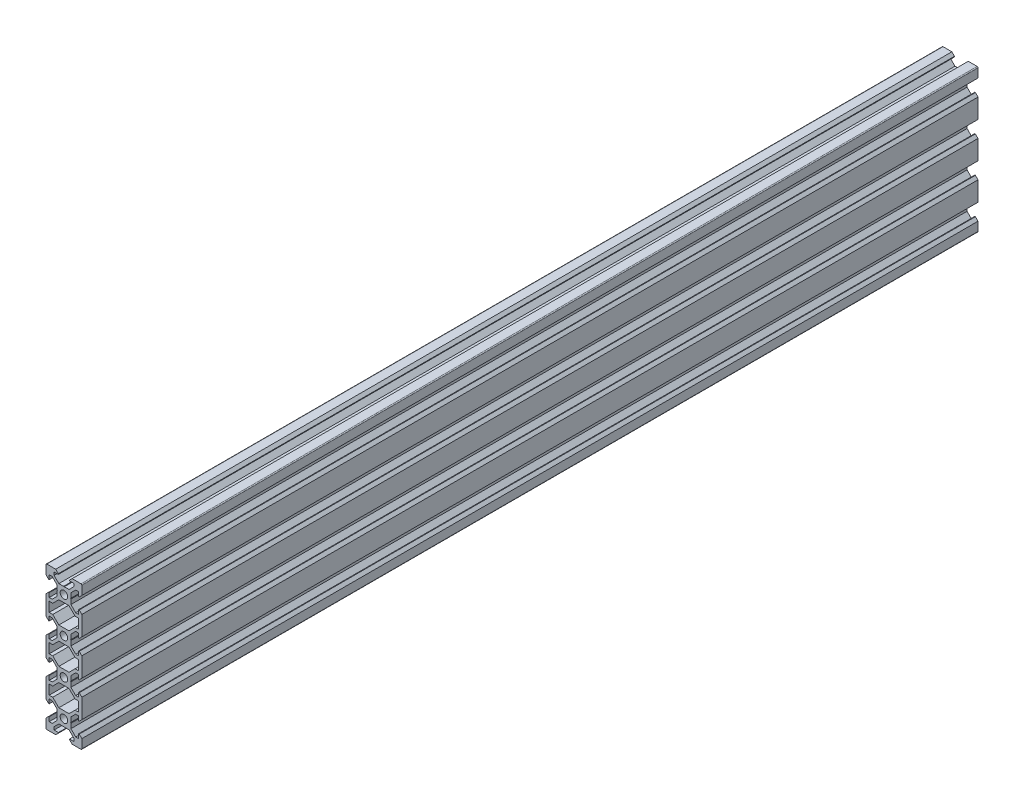
from build123d import *

# Parameters (mm, degrees)
SKETCH1_R           = 2.1
BOSS_EXTRUDE1_DEPTH = 500


with BuildPart() as part:
    # Sketch1 → Boss-Extrude1 (new body)
    with BuildSketch(Plane.XY):
        with BuildLine():
            Line((4.58, -40), (9.5, -40))
            ThreePointArc((9.5, -40), (9.853553391, -39.853553391), (10, -39.5))
            Line((10, -39.5), (10, -34.58))
            Line((10, -34.58), (8.545, -33.125))
            Line((8.545, -33.125), (8.2, -33.125))
            Line((8.2, -33.125), (8.2, -35.5))
            Line((8.2, -35.5), (6.560660172, -35.5))
            Line((6.560660172, -35.5), (3.9, -32.839339828))
            Line((3.9, -32.839339828), (3.9, -30.21))
            Line((3.9, -30.21), (3.69, -30))
            Line((3.69, -30), (3.9, -29.79))
            Line((3.9, -29.79), (3.9, -27.160660172))
            Line((3.9, -27.160660172), (6.560660172, -24.5))
            Line((6.560660172, -24.5), (8.2, -24.5))
            Line((8.2, -24.5), (8.2, -26.875))
            Line((8.2, -26.875), (8.545, -26.875))
            Line((8.545, -26.875), (10, -25.42))
            Line((10, -25.42), (10, -14.58))
            Line((10, -14.58), (8.545, -13.125))
            Line((8.545, -13.125), (8.2, -13.125))
            Line((8.2, -13.125), (8.2, -15.5))
            Line((8.2, -15.5), (6.560660172, -15.5))
            Line((6.560660172, -15.5), (3.9, -12.839339828))
            Line((3.9, -12.839339828), (3.9, -10.21))
            Line((3.9, -10.21), (3.69, -10))
            Line((3.69, -10), (3.9, -9.79))
            Line((3.9, -9.79), (3.9, -7.160660172))
            Line((3.9, -7.160660172), (6.560660172, -4.5))
            Line((6.560660172, -4.5), (8.2, -4.5))
            Line((8.2, -4.5), (8.2, -6.875))
            Line((8.2, -6.875), (8.545, -6.875))
            Line((8.545, -6.875), (10, -5.42))
            Line((10, -5.42), (10, 5.42))
            Line((10, 5.42), (8.545, 6.875))
            Line((8.545, 6.875), (8.2, 6.875))
            Line((8.2, 6.875), (8.2, 4.5))
            Line((8.2, 4.5), (6.560660172, 4.5))
            Line((6.560660172, 4.5), (3.9, 7.160660172))
            Line((3.9, 7.160660172), (3.9, 9.79))
            Line((3.9, 9.79), (3.69, 10))
            Line((3.69, 10), (3.9, 10.21))
            Line((3.9, 10.21), (3.9, 12.839339828))
            Line((3.9, 12.839339828), (6.560660172, 15.5))
            Line((6.560660172, 15.5), (8.2, 15.5))
            Line((8.2, 15.5), (8.2, 13.125))
            Line((8.2, 13.125), (8.545, 13.125))
            Line((8.545, 13.125), (10, 14.58))
            Line((10, 14.58), (10, 25.42))
            Line((10, 25.42), (8.545, 26.875))
            Line((8.545, 26.875), (8.2, 26.875))
            Line((8.2, 26.875), (8.2, 24.5))
            Line((8.2, 24.5), (6.560660172, 24.5))
            Line((6.560660172, 24.5), (3.9, 27.160660172))
            Line((3.9, 27.160660172), (3.9, 29.79))
            Line((3.9, 29.79), (3.69, 30))
            Line((3.69, 30), (3.9, 30.21))
            Line((3.9, 30.21), (3.9, 32.839339828))
            Line((3.9, 32.839339828), (6.560660172, 35.5))
            Line((6.560660172, 35.5), (8.2, 35.5))
            Line((8.2, 35.5), (8.2, 33.125))
            Line((8.2, 33.125), (8.545, 33.125))
            Line((8.545, 33.125), (10, 34.58))
            Line((10, 34.58), (10, 39.5))
            ThreePointArc((10, 39.5), (9.853553391, 39.853553391), (9.5, 40))
            Line((9.5, 40), (4.58, 40))
            Line((4.58, 40), (3.125, 38.545))
            Line((3.125, 38.545), (3.125, 38.2))
            Line((3.125, 38.2), (5.5, 38.2))
            Line((5.5, 38.2), (5.5, 36.560660172))
            Line((5.5, 36.560660172), (2.839339828, 33.9))
            Line((2.839339828, 33.9), (0.21, 33.9))
            Line((0.21, 33.9), (0, 33.69))
            Line((0, 33.69), (-0.21, 33.9))
            Line((-0.21, 33.9), (-2.839339828, 33.9))
            Line((-2.839339828, 33.9), (-5.5, 36.560660172))
            Line((-5.5, 36.560660172), (-5.5, 38.2))
            Line((-5.5, 38.2), (-3.125, 38.2))
            Line((-3.125, 38.2), (-3.125, 38.545))
            Line((-3.125, 38.545), (-4.58, 40))
            Line((-4.58, 40), (-9.5, 40))
            ThreePointArc((-9.5, 40), (-9.853553391, 39.853553391), (-10, 39.5))
            Line((-10, 39.5), (-10, 34.58))
            Line((-10, 34.58), (-8.545, 33.125))
            Line((-8.545, 33.125), (-8.2, 33.125))
            Line((-8.2, 33.125), (-8.2, 35.5))
            Line((-8.2, 35.5), (-6.560660172, 35.5))
            Line((-6.560660172, 35.5), (-3.9, 32.839339828))
            Line((-3.9, 32.839339828), (-3.9, 30.21))
            Line((-3.9, 30.21), (-3.69, 30))
            Line((-3.69, 30), (-3.9, 29.79))
            Line((-3.9, 29.79), (-3.9, 27.160660172))
            Line((-3.9, 27.160660172), (-6.560660172, 24.5))
            Line((-6.560660172, 24.5), (-8.2, 24.5))
            Line((-8.2, 24.5), (-8.2, 26.875))
            Line((-8.2, 26.875), (-8.545, 26.875))
            Line((-8.545, 26.875), (-10, 25.42))
            Line((-10, 25.42), (-10, 14.58))
            Line((-10, 14.58), (-8.545, 13.125))
            Line((-8.545, 13.125), (-8.2, 13.125))
            Line((-8.2, 13.125), (-8.2, 15.5))
            Line((-8.2, 15.5), (-6.560660172, 15.5))
            Line((-6.560660172, 15.5), (-3.9, 12.839339828))
            Line((-3.9, 12.839339828), (-3.9, 10.21))
            Line((-3.9, 10.21), (-3.69, 10))
            Line((-3.69, 10), (-3.9, 9.79))
            Line((-3.9, 9.79), (-3.9, 7.160660172))
            Line((-3.9, 7.160660172), (-6.560660172, 4.5))
            Line((-6.560660172, 4.5), (-8.2, 4.5))
            Line((-8.2, 4.5), (-8.2, 6.875))
            Line((-8.2, 6.875), (-8.545, 6.875))
            Line((-8.545, 6.875), (-10, 5.42))
            Line((-10, 5.42), (-10, -5.42))
            Line((-10, -5.42), (-8.545, -6.875))
            Line((-8.545, -6.875), (-8.2, -6.875))
            Line((-8.2, -6.875), (-8.2, -4.5))
            Line((-8.2, -4.5), (-6.560660172, -4.5))
            Line((-6.560660172, -4.5), (-3.9, -7.160660172))
            Line((-3.9, -7.160660172), (-3.9, -9.79))
            Line((-3.9, -9.79), (-3.69, -10))
            Line((-3.69, -10), (-3.9, -10.21))
            Line((-3.9, -10.21), (-3.9, -12.839339828))
            Line((-3.9, -12.839339828), (-6.560660172, -15.5))
            Line((-6.560660172, -15.5), (-8.2, -15.5))
            Line((-8.2, -15.5), (-8.2, -13.125))
            Line((-8.2, -13.125), (-8.545, -13.125))
            Line((-8.545, -13.125), (-10, -14.58))
            Line((-10, -14.58), (-10, -25.42))
            Line((-10, -25.42), (-8.545, -26.875))
            Line((-8.545, -26.875), (-8.2, -26.875))
            Line((-8.2, -26.875), (-8.2, -24.5))
            Line((-8.2, -24.5), (-6.560660172, -24.5))
            Line((-6.560660172, -24.5), (-3.9, -27.160660172))
            Line((-3.9, -27.160660172), (-3.9, -29.79))
            Line((-3.9, -29.79), (-3.69, -30))
            Line((-3.69, -30), (-3.9, -30.21))
            Line((-3.9, -30.21), (-3.9, -32.839339828))
            Line((-3.9, -32.839339828), (-6.560660172, -35.5))
            Line((-6.560660172, -35.5), (-8.2, -35.5))
            Line((-8.2, -35.5), (-8.2, -33.125))
            Line((-8.2, -33.125), (-8.545, -33.125))
            Line((-8.545, -33.125), (-10, -34.58))
            Line((-10, -34.58), (-10, -39.5))
            ThreePointArc((-10, -39.5), (-9.853553391, -39.853553391), (-9.5, -40))
            Line((-9.5, -40), (-4.58, -40))
            Line((-4.58, -40), (-3.125, -38.545))
            Line((-3.125, -38.545), (-3.125, -38.2))
            Line((-3.125, -38.2), (-5.5, -38.2))
            Line((-5.5, -38.2), (-5.5, -36.560660172))
            Line((-5.5, -36.560660172), (-2.839339828, -33.9))
            Line((-2.839339828, -33.9), (-0.21, -33.9))
            Line((-0.21, -33.9), (0, -33.69))
            Line((0, -33.69), (0.21, -33.9))
            Line((0.21, -33.9), (2.839339828, -33.9))
            Line((2.839339828, -33.9), (5.5, -36.560660172))
            Line((5.5, -36.560660172), (5.5, -38.2))
            Line((5.5, -38.2), (3.125, -38.2))
            Line((3.125, -38.2), (3.125, -38.545))
            Line((3.125, -38.545), (4.58, -40))
        make_face()
        with Locations((0, -30)):
            Circle(SKETCH1_R, mode=Mode.SUBTRACT)
        Polygon((-6.239339828, -22.7), (-8.2, -22.7), (-8.2, -17.3), (-6.239339828, -17.3), (-2.839339828, -13.9), (2.839339828, -13.9), (6.239339828, -17.3), (8.2, -17.3), (8.2, -22.7), (6.239339828, -22.7), (2.839339828, -26.1), (-2.839339828, -26.1), align=None, mode=Mode.SUBTRACT)
        with Locations((0, -10)):
            Circle(SKETCH1_R, mode=Mode.SUBTRACT)
        Polygon((-6.239339828, -2.7), (-8.2, -2.7), (-8.2, 2.7), (-6.239339828, 2.7), (-2.839339828, 6.1), (2.839339828, 6.1), (6.239339828, 2.7), (8.2, 2.7), (8.2, -2.7), (6.239339828, -2.7), (2.839339828, -6.1), (-2.839339828, -6.1), align=None, mode=Mode.SUBTRACT)
        with Locations((0, 10)):
            Circle(SKETCH1_R, mode=Mode.SUBTRACT)
        Polygon((-6.239339828, 17.3), (-8.2, 17.3), (-8.2, 22.7), (-6.239339828, 22.7), (-2.839339828, 26.1), (2.839339828, 26.1), (6.239339828, 22.7), (8.2, 22.7), (8.2, 17.3), (6.239339828, 17.3), (2.839339828, 13.9), (-2.839339828, 13.9), align=None, mode=Mode.SUBTRACT)
        with Locations((0, 30)):
            Circle(SKETCH1_R, mode=Mode.SUBTRACT)
    extrude(amount=BOSS_EXTRUDE1_DEPTH)


solid = part.part
